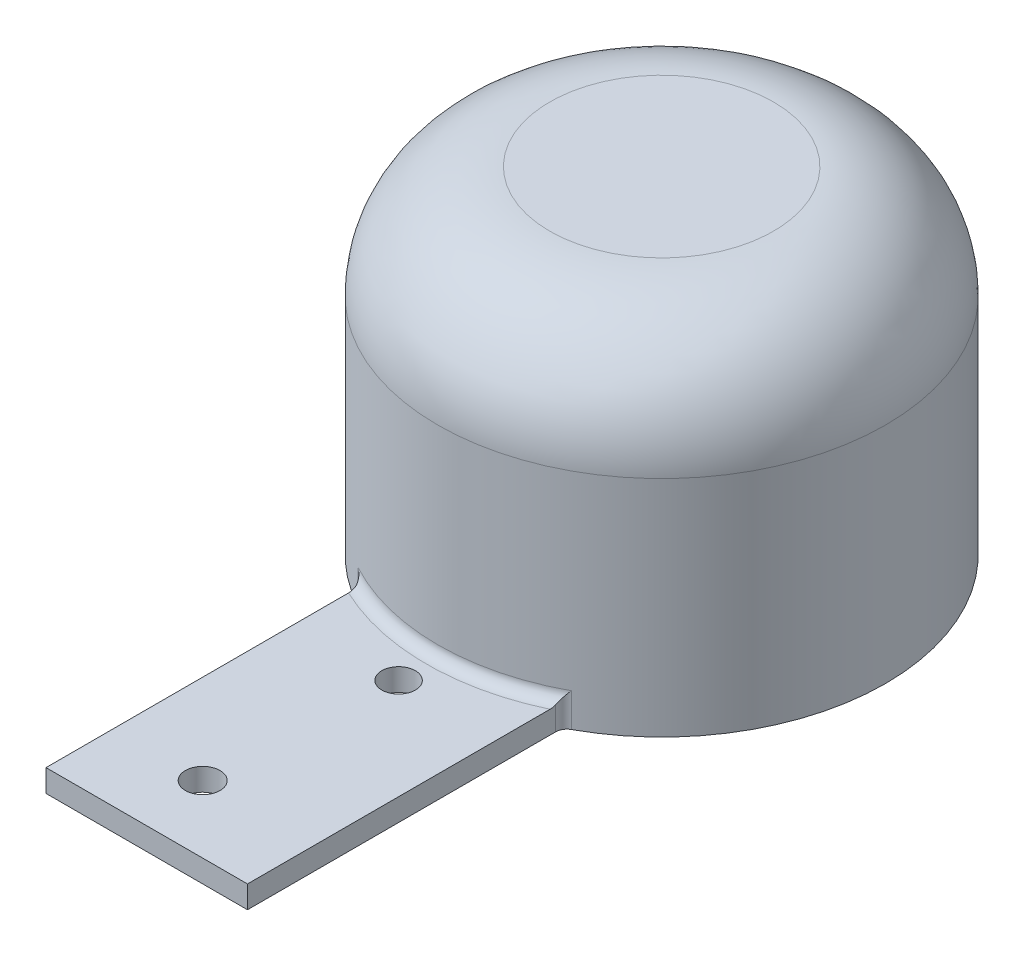
from build123d import *

# Parameters (mm, degrees)
SKETCH1_R           = 20
BOSS_EXTRUDE1_DEPTH = 30
BOSS_EXTRUDE2_DEPTH = 2
SKETCH3_R           = 1.55
SKETCH3_R_2         = 1.5
CUT_EXTRUDE1_DEPTH  = 2
FILLET1_R           = 1
FILLET2_R           = 10


with BuildPart() as part:
    # Sketch1 → Boss-Extrude1 (new body)
    with BuildSketch(Plane(origin=(0, 0, 0), x_dir=(1, 0, 0), z_dir=(0, 1, 0))):
        Circle(SKETCH1_R)
    extrude(amount=BOSS_EXTRUDE1_DEPTH)

    # Sketch2 → Boss-Extrude2 (add)
    with BuildSketch(Plane.XZ):
        with BuildLine():
            Line((-9, 46), (-9, 17.860571099))
            ThreePointArc((-9, 17.860571099), (0, 20), (9, 17.860571099))
            Line((9, 17.860571099), (9, 46))
            Line((9, 46), (-9, 46))
        make_face()
    extrude(amount=-BOSS_EXTRUDE2_DEPTH)

    # Sketch3 → Cut-Extrude1 (cut)
    with BuildSketch(Plane(origin=(0, 2, 0), x_dir=(1, 0, 0), z_dir=(0, 1, 0))):
        with Locations((-1, -40)):
            Circle(SKETCH3_R)
        with Locations((0, -23.5)):
            Circle(SKETCH3_R_2)
    extrude(amount=-CUT_EXTRUDE1_DEPTH, mode=Mode.SUBTRACT)

    # Fillet1
    fillet1_edges = [part.edges().sort_by_distance(p)[0] for p in [
        (-9, 1, 17.860571099),
        (0, 2, 20),
        (9, 1, 17.860571099),
    ]]
    fillet(fillet1_edges, radius=FILLET1_R)

    # Fillet2
    fillet2_edges = [part.edges().sort_by_distance(p)[0] for p in [
        (-20, 30, 0),
    ]]
    fillet(fillet2_edges, radius=FILLET2_R)


solid = part.part
